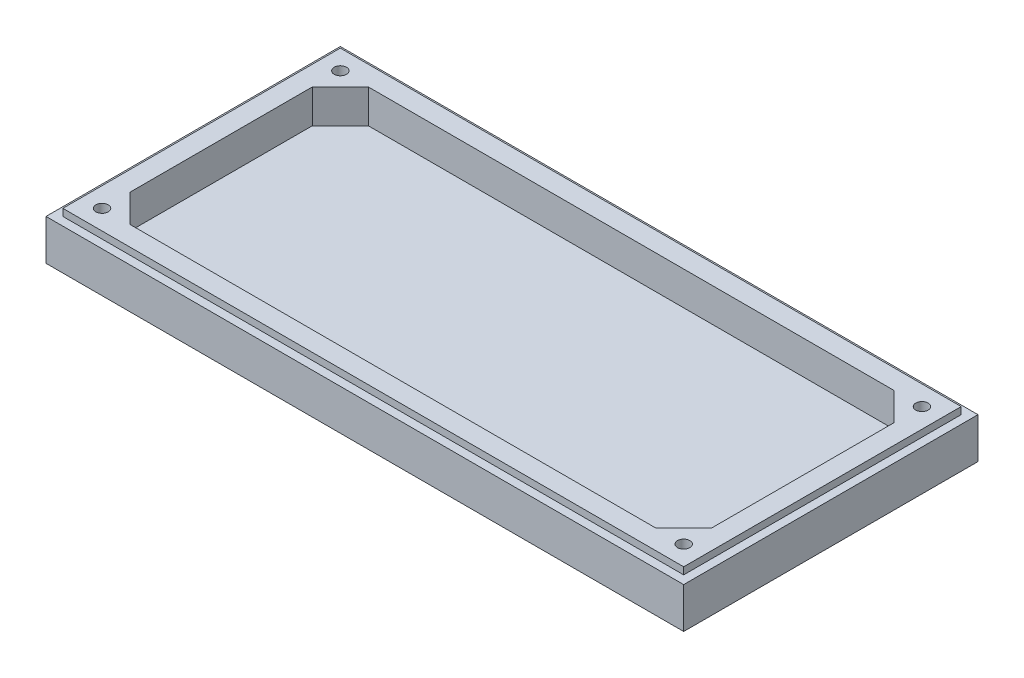
from build123d import *

# Parameters (mm, degrees)
SLABSKETCH_W            = 455
SLABSKETCH_H            = 210
SLAB_DEPTH              = 34
CUT_DEPTH               = 24
DIVOTSKETCH_OUTSIDE_W   = 557.456
DIVOTSKETCH_OUTSIDE_H   = 312.456
DIVOTSKETCH_OUTSIDE_W_2 = 443
DIVOTSKETCH_OUTSIDE_H_2 = 198
DIVOT_DEPTH             = 5
PILOTHOLESSKETCH_R      = 4.4
PILOTHOLES_DEPTH        = 20


with BuildPart() as part:
    # slabSketch → slab (new body)
    with BuildSketch(Plane(origin=(0, 0, 0), x_dir=(1, 0, 0), z_dir=(0, 1, 0))):
        with Locations((227.5, 105)):
            Rectangle(SLABSKETCH_W, SLABSKETCH_H)
    extrude(amount=-SLAB_DEPTH)

    # cutSketch → cut (cut)
    with BuildSketch(Plane(origin=(0, 0, 0), x_dir=(1, 0, 0), z_dir=(0, 1, 0))):
        Polygon((40, 190), (20, 170), (20, 40), (40, 20), (415, 20), (435, 40), (435, 170), (415, 190), align=None)
    extrude(amount=-CUT_DEPTH, mode=Mode.SUBTRACT)

    # divotSketch outside → divot (cut)
    with BuildSketch(Plane(origin=(0, 0, 0), x_dir=(1, 0, 0), z_dir=(0, 1, 0))):
        with Locations((227.5, 105)):
            Rectangle(DIVOTSKETCH_OUTSIDE_W, DIVOTSKETCH_OUTSIDE_H)
        with Locations((227.5, 105)):
            Rectangle(DIVOTSKETCH_OUTSIDE_W_2, DIVOTSKETCH_OUTSIDE_H_2, mode=Mode.SUBTRACT)
    extrude(amount=-DIVOT_DEPTH, mode=Mode.SUBTRACT)

    # pilotholesSketch → pilotholes (cut)
    with BuildSketch(Plane(origin=(0, 0, 0), x_dir=(1, 0, 0), z_dir=(0, 1, 0))):
        with Locations((20, 190)):
            Circle(PILOTHOLESSKETCH_R)
        with Locations((435, 190)):
            Circle(PILOTHOLESSKETCH_R)
        with Locations((435, 20)):
            Circle(PILOTHOLESSKETCH_R)
        with Locations((20, 20)):
            Circle(PILOTHOLESSKETCH_R)
    extrude(amount=-PILOTHOLES_DEPTH, mode=Mode.SUBTRACT)


solid = part.part
